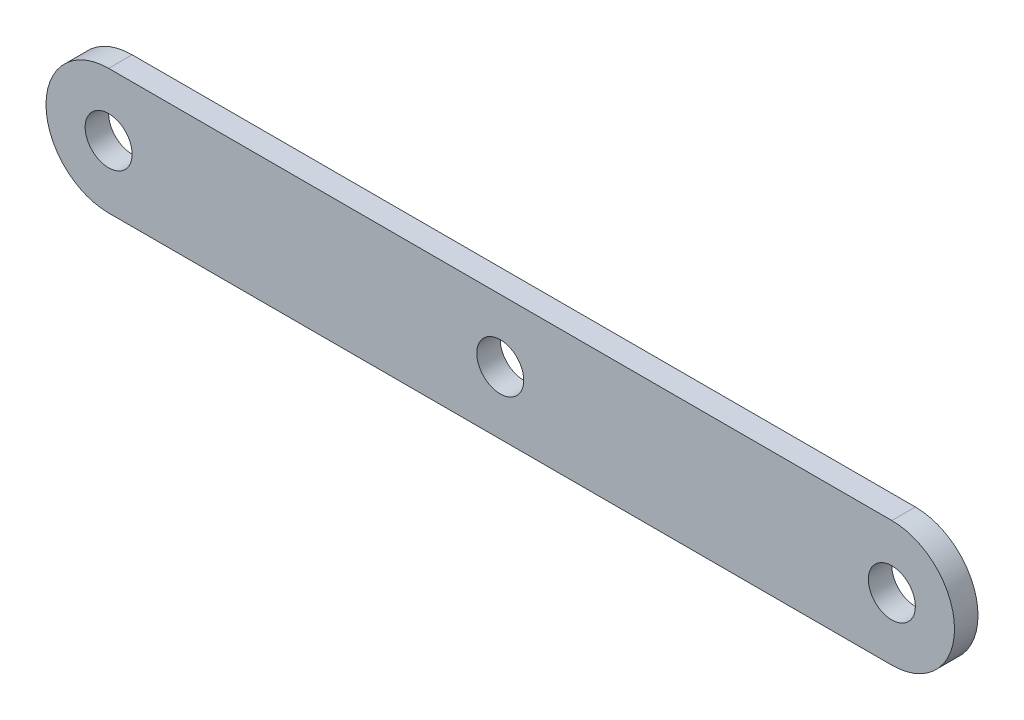
from build123d import *

# Parameters (mm, degrees)
SKETCH1_R           = 3
BOSS_EXTRUDE1_DEPTH = 3


with BuildPart() as part:
    # Sketch1 → Boss-Extrude1 (new body)
    with BuildSketch(Plane.XY):
        with BuildLine():
            Line((-50, 8), (50, 8))
            ThreePointArc((50, 8), (58, 0), (50, -8))
            Line((50, -8), (-50, -8))
            ThreePointArc((-50, -8), (-58, 0), (-50, 8))
        make_face()
        with Locations((-50, 0)):
            Circle(SKETCH1_R, mode=Mode.SUBTRACT)
        with Locations((50, 0)):
            Circle(SKETCH1_R, mode=Mode.SUBTRACT)
        Circle(SKETCH1_R, mode=Mode.SUBTRACT)
    extrude(amount=BOSS_EXTRUDE1_DEPTH)


solid = part.part
